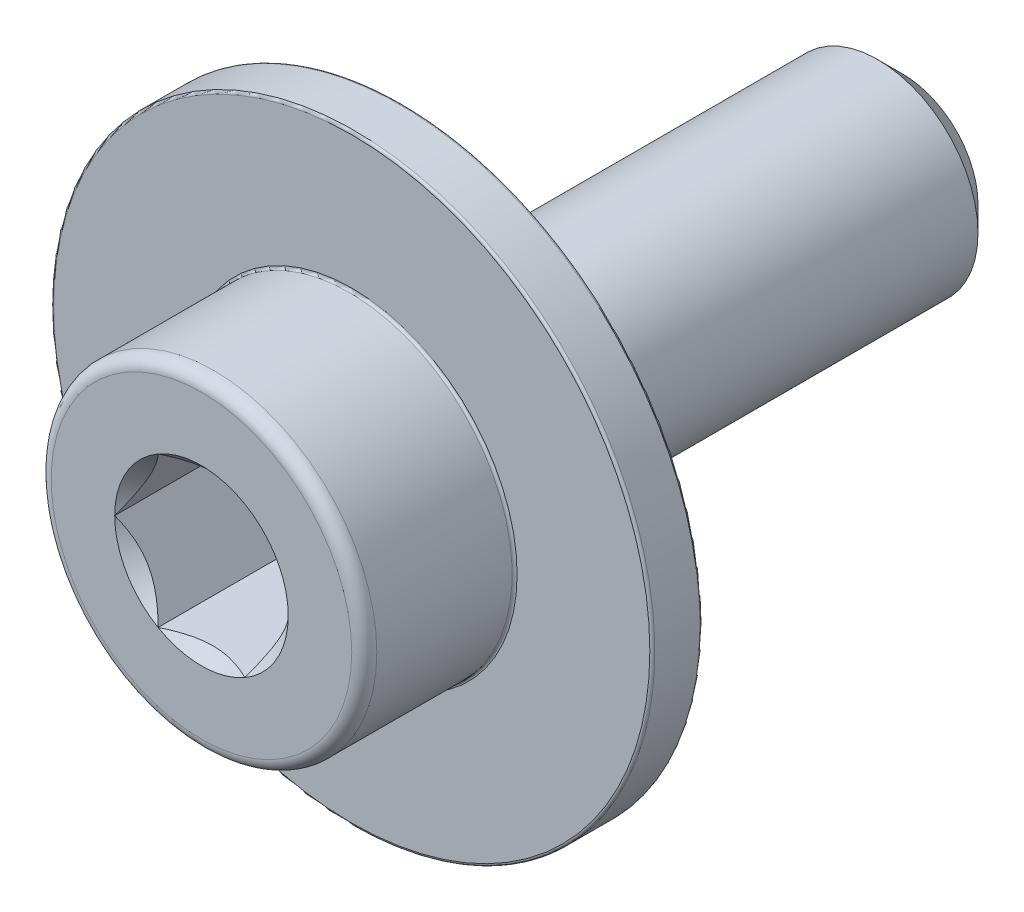
from build123d import *

# Parameters (mm, degrees)
SCHIZZO1_R                   = 4
ESTRUSIONE_ESTRUSIONE1_DEPTH = 20
SMUSSO1_SIZE                 = 1
SCHIZZO6_R                   = 6.5
ESTRUSIONE_ESTRUSIONE3_DEPTH = 8
TAGLIO_ESTRUSIONE3_DEPTH     = 6
SCHIZZO8_R                   = 3.464101615
TAGLIO_ESTRUSIONE4_DEPTH     = 1
TAGLIO_ESTRUSIONE4_TAPER     = 45
RACCORDO1_R                  = 0.5
SCHIZZO9_R                   = 12
SCHIZZO9_R_2                 = 6.5
ESTRUSIONE_ESTRUSIONE4_DEPTH = 2
RACCORDO2_R                  = 0.1


with BuildPart() as part:
    # Schizzo1 → Estrusione-Estrusione1 (new body)
    with BuildSketch(Plane.XY):
        Circle(SCHIZZO1_R)
    extrude(amount=ESTRUSIONE_ESTRUSIONE1_DEPTH)

    # Smusso1
    smusso1_edges = [part.edges().sort_by_distance(p)[0] for p in [
        (-4, 0, 0),
    ]]
    chamfer(smusso1_edges, length=SMUSSO1_SIZE)

    # Schizzo6 → Estrusione-Estrusione3 (add)
    with BuildSketch(Plane.XY.offset(20)):
        Circle(SCHIZZO6_R)
    extrude(amount=ESTRUSIONE_ESTRUSIONE3_DEPTH)

    # Schizzo7 → Taglio-Estrusione3 (cut)
    with BuildSketch(Plane.XY.offset(28)):
        Polygon((1.732050808, 3), (-1.732050808, 3), (-3.464101615, 0), (-1.732050808, -3), (1.732050808, -3), (3.464101615, 0), align=None)
    extrude(amount=-TAGLIO_ESTRUSIONE3_DEPTH, mode=Mode.SUBTRACT)

    # Schizzo8 → Taglio-Estrusione4 (cut)
    with BuildSketch(Plane.XY.offset(28)):
        Circle(SCHIZZO8_R)
    extrude(amount=-TAGLIO_ESTRUSIONE4_DEPTH, taper=TAGLIO_ESTRUSIONE4_TAPER, mode=Mode.SUBTRACT)

    # Raccordo1
    raccordo1_edges = [part.edges().sort_by_distance(p)[0] for p in [
        (-6.5, 0, 28),
    ]]
    fillet(raccordo1_edges, radius=RACCORDO1_R)

    # Schizzo9 → Estrusione-Estrusione4 (add)
    with BuildSketch(Plane(origin=(0, 0, 20), x_dir=(-1, 0, 0), z_dir=(0, 0, -1))):
        Circle(SCHIZZO9_R)
        Circle(SCHIZZO9_R_2, mode=Mode.SUBTRACT)
    extrude(amount=-ESTRUSIONE_ESTRUSIONE4_DEPTH)

    # Raccordo2
    raccordo2_edges = [part.edges().sort_by_distance(p)[0] for p in [
        (-6.5, 0, 22),
        (12, 0, 22),
        (12, 0, 20),
    ]]
    fillet(raccordo2_edges, radius=RACCORDO2_R)


solid = part.part
